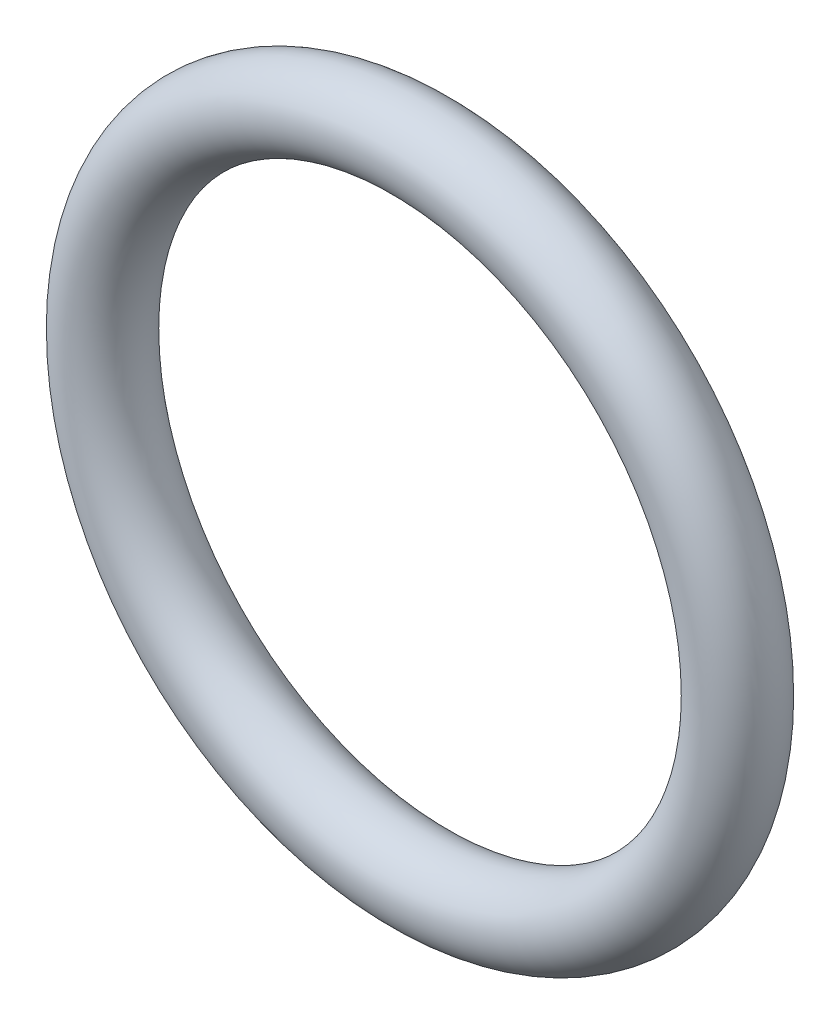
from build123d import *

# Parameters (mm, degrees)
SKETCH1_R = 0.889


with BuildPart() as part:
    # Sketch1 → Revolve1 (revolve)
    with BuildSketch(Plane(origin=(0, 0, 0), x_dir=(0, -1, 0), z_dir=(1, 0, 0))):
        with Locations((7.0993, 0)):
            Circle(SKETCH1_R)
    revolve(axis=Axis((0, 0, 0.889), (0, 0, -1)))


solid = part.part
